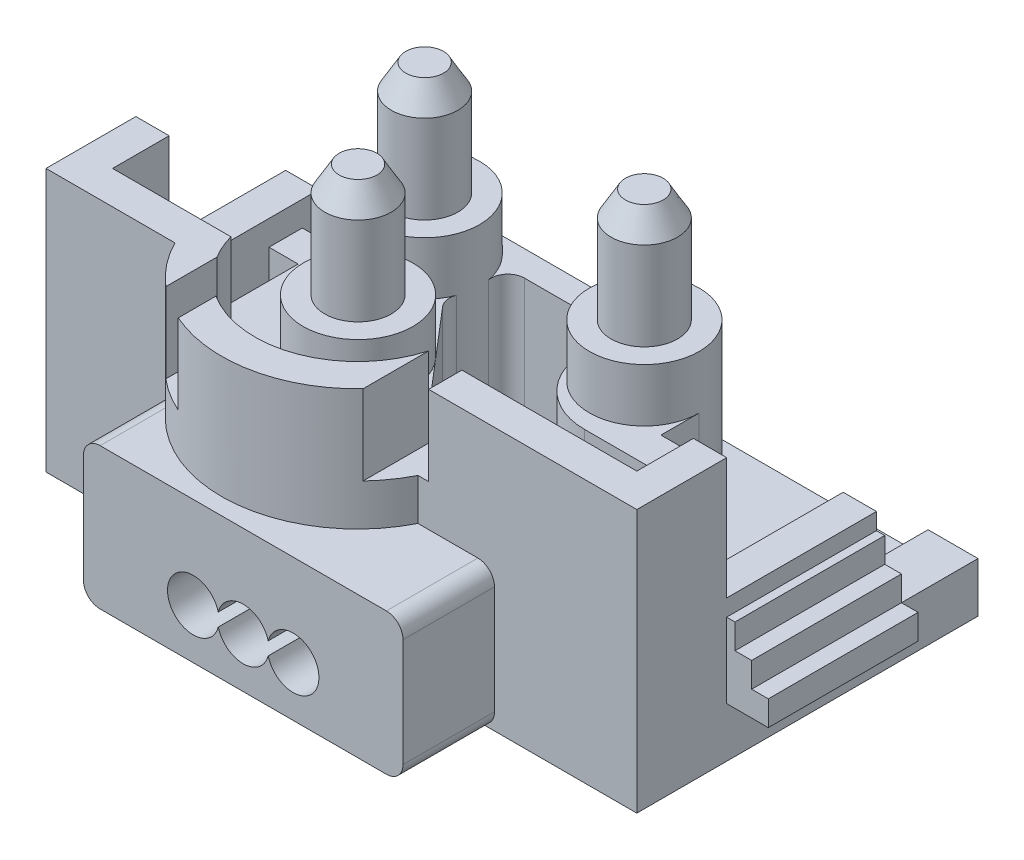
from build123d import *

# Parameters (mm, degrees)
SKETCH1_W             = 35.5
SKETCH1_H             = 20.5
BOSS_EXTRUDE1_DEPTH   = 1.5
BOSS_EXTRUDE2_DEPTH   = 1.5
BOSS_EXTRUDE4_DEPTH   = 9.5
SKETCH6_R             = 3.3
BOSS_EXTRUDE5_DEPTH   = 3.2
SKETCH7_R             = 2
BOSS_EXTRUDE6_DEPTH   = 6.8
BOSS_EXTRUDE6_2_DEPTH = 6.8
BOSS_EXTRUDE6_3_DEPTH = 6.8
CHAMFER1_SIZE         = 1.5
CHAMFER1_SIZE2        = 0.866025404
CHAMFER2_SIZE         = 1.5
CHAMFER2_SIZE2        = 0.866025404
CHAMFER3_SIZE         = 1.5
CHAMFER3_SIZE2        = 0.866025404
BOSS_EXTRUDE7_DEPTH   = 8
BOSS_EXTRUDE8_DEPTH   = 4.8
BOSS_EXTRUDE9_DEPTH   = 5.5
BOSS_EXTRUDE10_DEPTH  = 9
BOSS_EXTRUDE11_DEPTH  = 9
CUT_EXTRUDE4_DEPTH    = 5.5


with BuildPart() as part:
    # Sketch1 → Boss-Extrude1 (new body)
    with BuildSketch(Plane(origin=(0, 0, 0), x_dir=(1, 0, 0), z_dir=(0, 1, 0))):
        Rectangle(SKETCH1_W, SKETCH1_H)
    extrude(amount=BOSS_EXTRUDE1_DEPTH)

    # Sketch2 → Boss-Extrude2 (add)
    with BuildSketch(Plane(origin=(0, 1.5, 0), x_dir=(1, 0, 0), z_dir=(0, 1, 0))):
        Polygon((17.75, 10.25), (14.75, 10.25), (14.75, -8.25), (-14.75, -8.25), (-14.75, 10.25), (-17.75, 10.25), (-17.75, -10.25), (17.75, -10.25), align=None)
    extrude(amount=BOSS_EXTRUDE2_DEPTH)

    # Sketch4 → Boss-Extrude4 (add)
    with BuildSketch(Plane(origin=(0, 1.5, 0), x_dir=(1, 0, 0), z_dir=(0, 1, 0))):
        with BuildLine():
            ThreePointArc((9.8, 1.45), (8.833452378, 3.783452378), (6.5, 4.75))
            Line((6.5, 4.75), (-6.7, 4.75))
            ThreePointArc((-6.7, 4.75), (-9.033452378, 3.783452378), (-10, 1.45))
            Line((-10, 1.45), (-10, -0.85))
            Line((-10, -0.85), (-11.75, -0.85))
            Line((-11.75, -0.85), (-11.75, -2.85))
            Line((-11.75, -2.85), (-10, -2.85))
            Line((-10, -2.85), (-10, -8.25))
            Line((-10, -8.25), (3, -8.25))
            Line((3, -8.25), (-3.440516213, -0.729311618))
            ThreePointArc((-3.440516213, -0.729311618), (-3.666156861, -0.250346383), (-3.615628786, 0.276690914))
            ThreePointArc((-3.615628786, 0.276690914), (-3.413949819, 1.146892415), (-3.453044202, 2.03930302))
            ThreePointArc((-3.453044202, 2.03930302), (-3.236769385, 2.858747591), (-2.469118203, 3.217879692))
            Line((-2.469118203, 3.217879692), (2.269118203, 3.217879692))
            ThreePointArc((2.269118203, 3.217879692), (3.036769385, 2.858747591), (3.253044202, 2.03930302))
            ThreePointArc((3.253044202, 2.03930302), (3.213287803, 1.745842752), (3.2, 1.45))
            Line((3.2, 1.45), (3.2, 1.15))
            ThreePointArc((3.2, 1.15), (4.371572875, -1.678427125), (7.2, -2.85))
            Line((7.2, -2.85), (9.8, -2.85))
            Line((9.8, -2.85), (11.55, -2.85))
            Line((11.55, -2.85), (11.55, -0.85))
            Line((11.55, -0.85), (9.8, -0.85))
            Line((9.8, -0.85), (9.8, 1.45))
        make_face()
        with BuildLine():
            Line((3, -8.25), (-10, -8.25))
            Line((-10, -8.25), (-10, -10.25))
            ThreePointArc((-10, -10.25), (-2.7, -14.75), (4.6, -10.25))
            Line((4.6, -10.25), (4.6, -8.25))
            Line((4.6, -8.25), (3, -8.25))
        make_face()
    extrude(amount=BOSS_EXTRUDE4_DEPTH)

    # Sketch6 → Boss-Extrude5 (add)
    with BuildSketch(Plane(origin=(0, 11, 0), x_dir=(1, 0, 0), z_dir=(0, 1, 0))):
        with Locations((-6.7, 1.45)):
            Circle(SKETCH6_R)
        with Locations((6.5, 1.45)):
            Circle(SKETCH6_R)
        with Locations((-3.4, -5.85)):
            Circle(SKETCH6_R)
    extrude(amount=BOSS_EXTRUDE5_DEPTH)

    # Sketch8 → Boss-Extrude7 (add)
    with BuildSketch(Plane(origin=(0, 3, 0), x_dir=(1, 0, 0), z_dir=(0, 1, 0))):
        with BuildLine():
            Line((-17.75, -10.25), (-10, -10.25))
            ThreePointArc((-10, -10.25), (-2.7, -14.75), (4.6, -10.25))
            Line((4.6, -10.25), (17.75, -10.25))
            Line((17.75, -10.25), (17.75, -4.85))
            Line((17.75, -4.85), (15.75, -4.85))
            Line((15.75, -4.85), (15.75, -8.25))
            Line((15.75, -8.25), (14.75, -8.25))
            Line((14.75, -8.25), (4.6, -8.25))
            Line((4.6, -8.25), (3.240538696, -8.25))
            ThreePointArc((3.240538696, -8.25), (-2.7, -12.75), (-8.640538696, -8.25))
            Line((-8.640538696, -8.25), (-10, -8.25))
            Line((-10, -8.25), (-14.75, -8.25))
            Line((-14.75, -8.25), (-15.75, -8.25))
            Line((-15.75, -8.25), (-15.75, -4.85))
            Line((-15.75, -4.85), (-17.75, -4.85))
            Line((-17.75, -4.85), (-17.75, -10.25))
        make_face()
    extrude(amount=BOSS_EXTRUDE7_DEPTH)

    # Sketch9 → Boss-Extrude8 (add)
    with BuildSketch(Plane(origin=(0, 11, 0), x_dir=(1, 0, 0), z_dir=(0, 1, 0))):
        Polygon((17.75, -10.25), (17.75, -4.85), (15.75, -4.85), (15.75, -8.25), (5.240538696, -8.25), (5.240538696, -10.25), align=None)
        with BuildLine():
            Line((-17.75, -4.85), (-17.75, -10.25))
            Line((-17.75, -10.25), (-10, -10.25))
            ThreePointArc((-10, -10.25), (-9.127522593, -11.624085625), (-8, -12.797976988))
            Line((-8, -12.797976988), (-8, -9.739998243))
            ThreePointArc((-8, -9.739998243), (-8.369431297, -9.016133462), (-8.640538696, -8.25))
            Line((-8.640538696, -8.25), (-15.75, -8.25))
            Line((-15.75, -8.25), (-15.75, -4.85))
            Line((-15.75, -4.85), (-17.75, -4.85))
        make_face()
        with BuildLine():
            Line((3.240538696, -8.25), (3.240538696, -12.189330653))
            ThreePointArc((3.240538696, -12.189330653), (-1.083725026, -14.588552552), (-6, -14.05398466))
            Line((-6, -14.05398466), (-6, -11.793542506))
            ThreePointArc((-6, -11.793542506), (-0.490410779, -12.340861452), (3.240538696, -8.25))
        make_face()
    extrude(amount=BOSS_EXTRUDE8_DEPTH)

    # Sketch10 → Boss-Extrude9 (add)
    with BuildSketch(Plane.XY.offset(10.25)):
        with BuildLine():
            Line((-10, 1), (-10, 7.5))
            ThreePointArc((-10, 7.5), (-9.707106781, 8.207106781), (-9, 8.5))
            Line((-9, 8.5), (8.2, 8.5))
            ThreePointArc((8.2, 8.5), (8.907106781, 8.207106781), (9.2, 7.5))
            Line((9.2, 7.5), (9.2, 1))
            ThreePointArc((9.2, 1), (8.907106781, 0.292893219), (8.2, 0))
            Line((8.2, 0), (-9, 0))
            ThreePointArc((-9, 0), (-9.707106781, 0.292893219), (-10, 1))
        make_face()
    extrude(amount=BOSS_EXTRUDE9_DEPTH)

    # Sketch11 → Boss-Extrude10 (add)
    with BuildSketch(Plane(origin=(0, 0, 4.85), x_dir=(-1, 0, 0), z_dir=(0, 0, -1))):
        Polygon((-15.75, 8.5), (-17.75, 8.5), (-17.75, 7.5), (-18.25, 7.5), (-18.25, 6), (-19.25, 6), (-19.25, 4.5), (-20.25, 4.5), (-20.25, 3), (-15.75, 3), align=None)
        Polygon((20.25, 4.5), (20.25, 3), (15.75, 3), (15.75, 8.5), (17.75, 8.5), (17.75, 7.5), (18.25, 7.5), (18.25, 6), (19.25, 6), (19.25, 4.5), align=None)
    extrude(amount=BOSS_EXTRUDE10_DEPTH)

    # Sketch12 → Boss-Extrude11 (add)
    with BuildSketch(Plane(origin=(0, 0, 8.25), x_dir=(-1, 0, 0), z_dir=(0, 0, -1))):
        with BuildLine():
            Line((-8.75, 1.5), (-8.75, 6.6))
            ThreePointArc((-8.75, 6.6), (-8.047056275, 8.297056275), (-6.35, 9))
            Line((-6.35, 9), (-6.15, 9))
            ThreePointArc((-6.15, 9), (-4.452943725, 8.297056275), (-3.75, 6.6))
            Line((-3.75, 6.6), (-3.75, 1.5))
            Line((-3.75, 1.5), (-8.75, 1.5))
        make_face()
    extrude(amount=BOSS_EXTRUDE11_DEPTH)

    # Sketch13 → Cut-Extrude4 (cut)
    with BuildSketch(Plane.XY.offset(15.75)):
        with BuildLine():
            ThreePointArc((-1.9, 2.609487516), (-0.4, 1.45), (1.1, 2.609487516))
            ThreePointArc((1.1, 2.609487516), (4.15, 3), (1.1, 3.390512484))
            ThreePointArc((1.1, 3.390512484), (-0.4, 4.55), (-1.9, 3.390512484))
            ThreePointArc((-1.9, 3.390512484), (-4.95, 3), (-1.9, 2.609487516))
        make_face()
    extrude(amount=-CUT_EXTRUDE4_DEPTH, mode=Mode.SUBTRACT)


with BuildPart() as body_2:
    # Sketch7 → Boss-Extrude6 (new body)
    with BuildSketch(Plane(origin=(0, 14.2, 0), x_dir=(1, 0, 0), z_dir=(0, 1, 0))):
        with Locations((-6.7, 1.45)):
            Circle(SKETCH7_R)
    extrude(amount=BOSS_EXTRUDE6_DEPTH)

    # Chamfer3
    chamfer3_edges = [body_2.edges().sort_by_distance(p)[0] for p in [
        (-8.7, 21, -1.45),
    ]]
    chamfer3_side = [body_2.faces().sort_by_distance(p)[0] for p in [
        (-8.7, 17.6, -1.45),
    ]]
    chamfer(chamfer3_edges, length=CHAMFER3_SIZE, length2=CHAMFER3_SIZE2, reference=chamfer3_side[0])


with BuildPart() as body_3:
    # Sketch7 → Boss-Extrude6 2 (new body)
    with BuildSketch(Plane(origin=(0, 14.2, 0), x_dir=(1, 0, 0), z_dir=(0, 1, 0))):
        with Locations((-3.4, -5.85)):
            Circle(SKETCH7_R)
    extrude(amount=BOSS_EXTRUDE6_2_DEPTH)

    # Chamfer1
    chamfer1_edges = [body_3.edges().sort_by_distance(p)[0] for p in [
        (-5.4, 21, 5.85),
    ]]
    chamfer1_side = [body_3.faces().sort_by_distance(p)[0] for p in [
        (-5.4, 17.6, 5.85),
    ]]
    chamfer(chamfer1_edges, length=CHAMFER1_SIZE, length2=CHAMFER1_SIZE2, reference=chamfer1_side[0])


with BuildPart() as body_4:
    # Sketch7 → Boss-Extrude6 3 (new body)
    with BuildSketch(Plane(origin=(0, 14.2, 0), x_dir=(1, 0, 0), z_dir=(0, 1, 0))):
        with Locations((6.5, 1.45)):
            Circle(SKETCH7_R)
    extrude(amount=BOSS_EXTRUDE6_3_DEPTH)

    # Chamfer2
    chamfer2_edges = [body_4.edges().sort_by_distance(p)[0] for p in [
        (4.5, 21, -1.45),
    ]]
    chamfer2_side = [body_4.faces().sort_by_distance(p)[0] for p in [
        (4.5, 17.6, -1.45),
    ]]
    chamfer(chamfer2_edges, length=CHAMFER2_SIZE, length2=CHAMFER2_SIZE2, reference=chamfer2_side[0])


solid = Compound([part.part, body_2.part, body_3.part, body_4.part])
